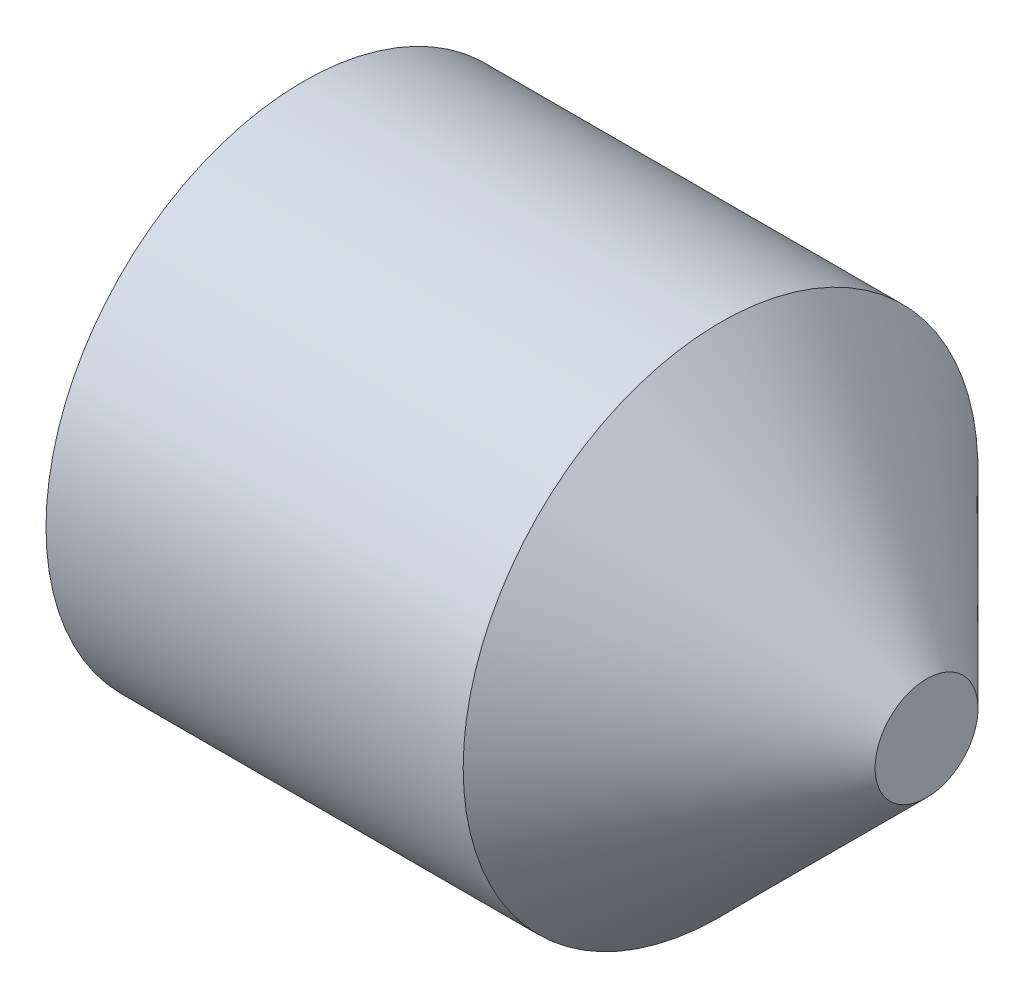
from build123d import *

# Parameters (mm, degrees)
HEX_2_DEPTH = 10


with BuildPart() as part:
    # BodySke → BaseBody (revolve)
    with BuildSketch(Plane.XY):
        Polygon((0, 0), (0, 10.352), (0.951473244, 12), (20.4, 12), (30, 2.4), (30, 0), align=None)
    revolve(axis=Axis((-12.7, 0, 0), (1, 0, 0)))

    # Sketch2 → Hex 2 (cut)
    with BuildSketch(Plane.ZY):
        Polygon((3.464101615, 6), (-3.464101615, 6), (-6.92820323, 0), (-3.464101615, -6), (3.464101615, -6), (6.92820323, 0), align=None)
    extrude(amount=-HEX_2_DEPTH, mode=Mode.SUBTRACT)


solid = part.part
